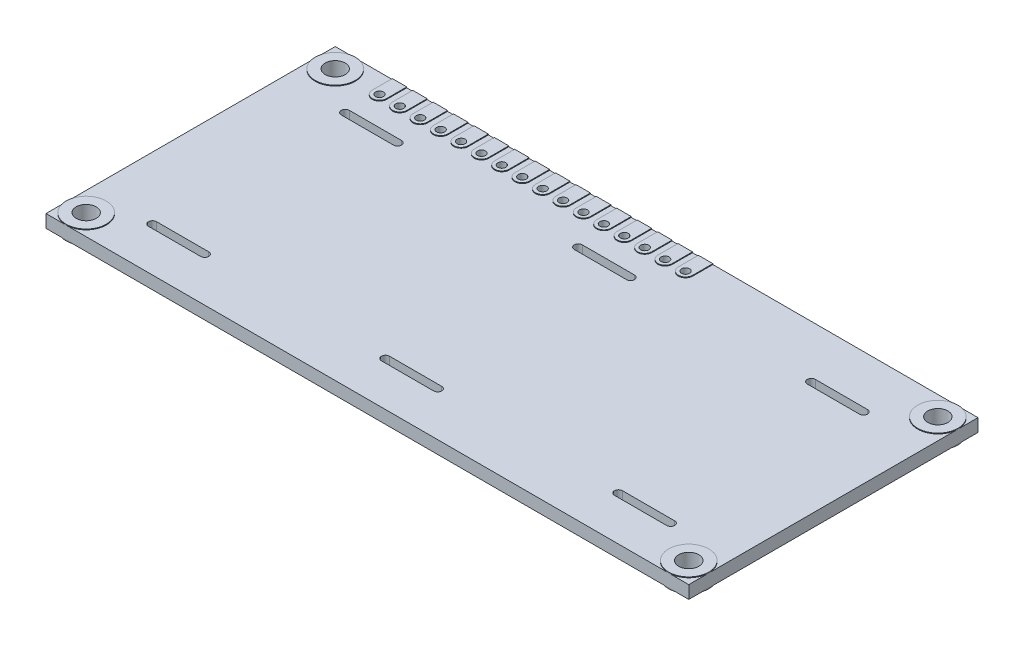
from build123d import *

# Parameters (mm, degrees)
SKETCH1_W           = 80
SKETCH1_H           = 36
SKETCH1_R           = 1.25
SKETCH1_R_2         = 0.5
BOSS_EXTRUDE1_DEPTH = 1.6
SKETCH2_R           = 0.5
BOSS_EXTRUDE2_DEPTH = 0.1
LPATTERN1_COUNT     = 16
LPATTERN1_PITCH     = 2.54
SKETCH3_R           = 2.5
SKETCH3_R_2         = 1.25
BOSS_EXTRUDE3_DEPTH = 0.1
SKETCH4_R           = 2.5
SKETCH4_R_2         = 1.25
BOSS_EXTRUDE4_DEPTH = 0.1


with BuildPart() as part:
    # Sketch1 → Boss-Extrude1 (new body)
    with BuildSketch(Plane(origin=(0, 0, 0), x_dir=(1, 0, 0), z_dir=(0, 1, 0))):
        Rectangle(SKETCH1_W, SKETCH1_H)
        with Locations((-37.5, 15.5)):
            Circle(SKETCH1_R, mode=Mode.SUBTRACT)
        with Locations((-37.5, -15.5)):
            Circle(SKETCH1_R, mode=Mode.SUBTRACT)
        with Locations((37.5, 15.5)):
            Circle(SKETCH1_R, mode=Mode.SUBTRACT)
        with Locations((37.5, -15.5)):
            Circle(SKETCH1_R, mode=Mode.SUBTRACT)
        with Locations((-32, 15.5)):
            Circle(SKETCH1_R_2, mode=Mode.SUBTRACT)
        with Locations((-29.46, 15.5)):
            Circle(SKETCH1_R_2, mode=Mode.SUBTRACT)
        with Locations((-26.92, 15.5)):
            Circle(SKETCH1_R_2, mode=Mode.SUBTRACT)
        with Locations((-24.38, 15.5)):
            Circle(SKETCH1_R_2, mode=Mode.SUBTRACT)
        with Locations((-21.84, 15.5)):
            Circle(SKETCH1_R_2, mode=Mode.SUBTRACT)
        with Locations((-19.3, 15.5)):
            Circle(SKETCH1_R_2, mode=Mode.SUBTRACT)
        with Locations((-16.76, 15.5)):
            Circle(SKETCH1_R_2, mode=Mode.SUBTRACT)
        with Locations((-14.22, 15.5)):
            Circle(SKETCH1_R_2, mode=Mode.SUBTRACT)
        with Locations((-11.68, 15.5)):
            Circle(SKETCH1_R_2, mode=Mode.SUBTRACT)
        with Locations((-9.14, 15.5)):
            Circle(SKETCH1_R_2, mode=Mode.SUBTRACT)
        with Locations((-6.6, 15.5)):
            Circle(SKETCH1_R_2, mode=Mode.SUBTRACT)
        with Locations((-4.06, 15.5)):
            Circle(SKETCH1_R_2, mode=Mode.SUBTRACT)
        with Locations((-1.52, 15.5)):
            Circle(SKETCH1_R_2, mode=Mode.SUBTRACT)
        with Locations((1.02, 15.5)):
            Circle(SKETCH1_R_2, mode=Mode.SUBTRACT)
        with Locations((3.56, 15.5)):
            Circle(SKETCH1_R_2, mode=Mode.SUBTRACT)
        with Locations((6.1, 15.5)):
            Circle(SKETCH1_R_2, mode=Mode.SUBTRACT)
        with BuildLine():
            Line((-3.25, -12), (3.25, -12))
            ThreePointArc((3.25, -12), (3.75, -12.5), (3.25, -13))
            Line((3.25, -13), (-3.25, -13))
            ThreePointArc((-3.25, -13), (-3.75, -12.5), (-3.25, -12))
        make_face(mode=Mode.SUBTRACT)
        with BuildLine():
            Line((25.75, -12), (32.25, -12))
            ThreePointArc((32.25, -12), (32.75, -12.5), (32.25, -13))
            Line((32.25, -13), (25.75, -13))
            ThreePointArc((25.75, -13), (25.25, -12.5), (25.75, -12))
        make_face(mode=Mode.SUBTRACT)
        with BuildLine():
            Line((25.75, 12), (32.25, 12))
            ThreePointArc((32.25, 12), (32.75, 11.5), (32.25, 11))
            Line((32.25, 11), (25.75, 11))
            ThreePointArc((25.75, 11), (25.25, 11.5), (25.75, 12))
        make_face(mode=Mode.SUBTRACT)
        with BuildLine():
            Line((-3.25, 12), (3.25, 12))
            ThreePointArc((3.25, 12), (3.75, 11.5), (3.25, 11))
            Line((3.25, 11), (-3.25, 11))
            ThreePointArc((-3.25, 11), (-3.75, 11.5), (-3.25, 12))
        make_face(mode=Mode.SUBTRACT)
        with BuildLine():
            Line((-32.25, -12), (-25.75, -12))
            ThreePointArc((-25.75, -12), (-25.25, -12.5), (-25.75, -13))
            Line((-25.75, -13), (-32.25, -13))
            ThreePointArc((-32.25, -13), (-32.75, -12.5), (-32.25, -12))
        make_face(mode=Mode.SUBTRACT)
        with BuildLine():
            Line((-32.25, 12), (-25.75, 12))
            ThreePointArc((-25.75, 12), (-25.25, 11.5), (-25.75, 11))
            Line((-25.75, 11), (-32.25, 11))
            ThreePointArc((-32.25, 11), (-32.75, 11.5), (-32.25, 12))
        make_face(mode=Mode.SUBTRACT)
    extrude(amount=-BOSS_EXTRUDE1_DEPTH)

    # Sketch2 → Boss-Extrude2 (add)
    with BuildSketch(Plane(origin=(0, 0, 0), x_dir=(1, 0, 0), z_dir=(0, 1, 0))):
        with BuildLine():
            Line((-32.9, 15.5), (-32.9, 18))
            Line((-32.9, 18), (-31.1, 18))
            Line((-31.1, 18), (-31.1, 15.5))
            ThreePointArc((-31.1, 15.5), (-32, 14.6), (-32.9, 15.5))
        make_face()
        with Locations((-32, 15.5)):
            Circle(SKETCH2_R, mode=Mode.SUBTRACT)
    boss_extrude2 = extrude(amount=BOSS_EXTRUDE2_DEPTH)

    # LPattern1: Boss-Extrude2 ×16
    with Locations(*[(i * LPATTERN1_PITCH, 0, 0) for i in range(1, LPATTERN1_COUNT)]):
        add(boss_extrude2)

    # Sketch3 → Boss-Extrude3 (add)
    with BuildSketch(Plane(origin=(0, 0, 0), x_dir=(1, 0, 0), z_dir=(0, 1, 0))):
        with Locations((-37.5, 15.5)):
            Circle(SKETCH3_R)
        with Locations((-37.5, 15.5)):
            Circle(SKETCH3_R_2, mode=Mode.SUBTRACT)
        with Locations((-37.5, -15.5)):
            Circle(SKETCH3_R)
        with Locations((-37.5, -15.5)):
            Circle(SKETCH3_R_2, mode=Mode.SUBTRACT)
        with Locations((37.5, -15.5)):
            Circle(SKETCH3_R)
        with Locations((37.5, -15.5)):
            Circle(SKETCH3_R_2, mode=Mode.SUBTRACT)
        with Locations((37.5, 15.5)):
            Circle(SKETCH3_R)
        with Locations((37.5, 15.5)):
            Circle(SKETCH3_R_2, mode=Mode.SUBTRACT)
    extrude(amount=BOSS_EXTRUDE3_DEPTH)

    # Sketch4 → Boss-Extrude4 (add)
    with BuildSketch(Plane.XZ.offset(1.6)):
        with Locations((37.5, -15.5)):
            Circle(SKETCH4_R)
        with Locations((37.5, -15.5)):
            Circle(SKETCH4_R_2, mode=Mode.SUBTRACT)
        with Locations((37.5, 15.5)):
            Circle(SKETCH4_R)
        with Locations((37.5, 15.5)):
            Circle(SKETCH4_R_2, mode=Mode.SUBTRACT)
        with Locations((-37.5, 15.5)):
            Circle(SKETCH4_R)
        with Locations((-37.5, 15.5)):
            Circle(SKETCH4_R_2, mode=Mode.SUBTRACT)
        with Locations((-37.5, -15.5)):
            Circle(SKETCH4_R)
        with Locations((-37.5, -15.5)):
            Circle(SKETCH4_R_2, mode=Mode.SUBTRACT)
    extrude(amount=BOSS_EXTRUDE4_DEPTH)


solid = part.part
